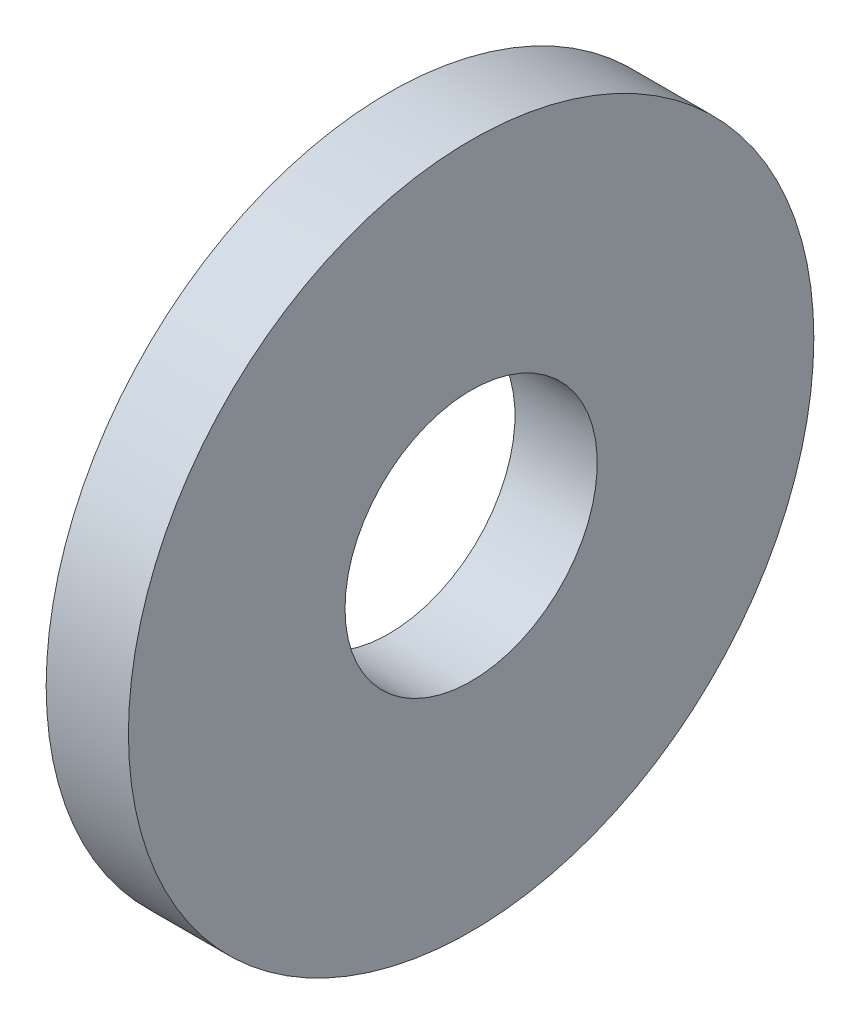
from build123d import *

# Parameters (mm, degrees)
SKETCH1_W = 1.2
SKETCH1_H = 3.16


with BuildPart() as part:
    # Sketch1 → Base-Revolve (revolve)
    with BuildSketch(Plane.XY):
        with Locations((-0.6, 3.42)):
            Rectangle(SKETCH1_W, SKETCH1_H)
    revolve(axis=Axis((-34.925, 0, 0), (1, 0, 0)))


solid = part.part
